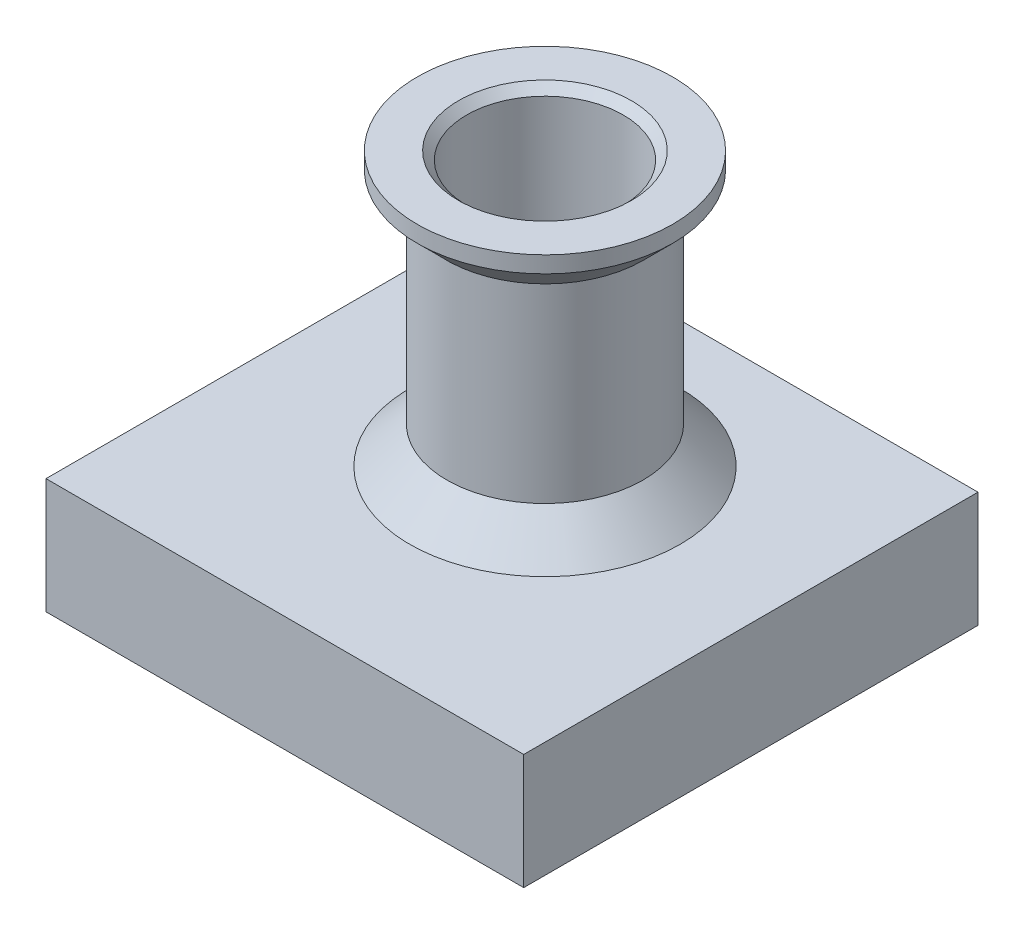
from build123d import *

# Parameters (mm, degrees)
SKETCH2_OUTSIDE_W       = 59.31
SKETCH2_OUTSIDE_H       = 59.31
SKETCH2_OUTSIDE_W_2     = 28.986815524
SKETCH2_OUTSIDE_H_2     = 27.563826398
CUT_EXTRUDE1_DEPTH      = 11
CUT_EXTRUDE1_DEPTH_BACK = 14.593473012
SKETCH3_W               = 17
SKETCH3_H               = 17
CUT_EXTRUDE2_DEPTH      = 6.5


with BuildPart() as part:
    # Sketch1 → Revolve1 (revolve)
    with BuildSketch(Plane.XY):
        Polygon((4.75, 9.5), (4.75, 0), (3.6, -1.15), (3.6, -13.593473012), (22, -13.593473012), (22, -6.593473012), (8.200842899, -6.593473012), (5.95, -4.342630114), (5.95, 7.2), (7.75, 9), (7.75, 10), (5.25, 10), align=None)
    revolve(axis=Axis((0, -12.923275862, 0), (0, 1, 0)))

    # Sketch2 outside → Cut-Extrude1 (cut, two sides)
    with BuildSketch(Plane(origin=(0, 0, 0), x_dir=(1, 0, 0), z_dir=(0, 1, 0))) as cut_extrude1_sk:
        Rectangle(SKETCH2_OUTSIDE_W, SKETCH2_OUTSIDE_H)
        with Locations((0, -2)):
            Rectangle(SKETCH2_OUTSIDE_W_2, SKETCH2_OUTSIDE_H_2, mode=Mode.SUBTRACT)
    extrude(amount=CUT_EXTRUDE1_DEPTH, mode=Mode.SUBTRACT)
    extrude(cut_extrude1_sk.sketch, amount=-CUT_EXTRUDE1_DEPTH_BACK, mode=Mode.SUBTRACT)

    # Sketch3 → Cut-Extrude2 (cut)
    with BuildSketch(Plane(origin=(0, -14.593473012, 0), x_dir=(-1, 0, 0), z_dir=(0, -1, 0))):
        with Locations((0, -4.215)):
            Rectangle(SKETCH3_W, SKETCH3_H)
    extrude(amount=-CUT_EXTRUDE2_DEPTH, mode=Mode.SUBTRACT)


solid = part.part
